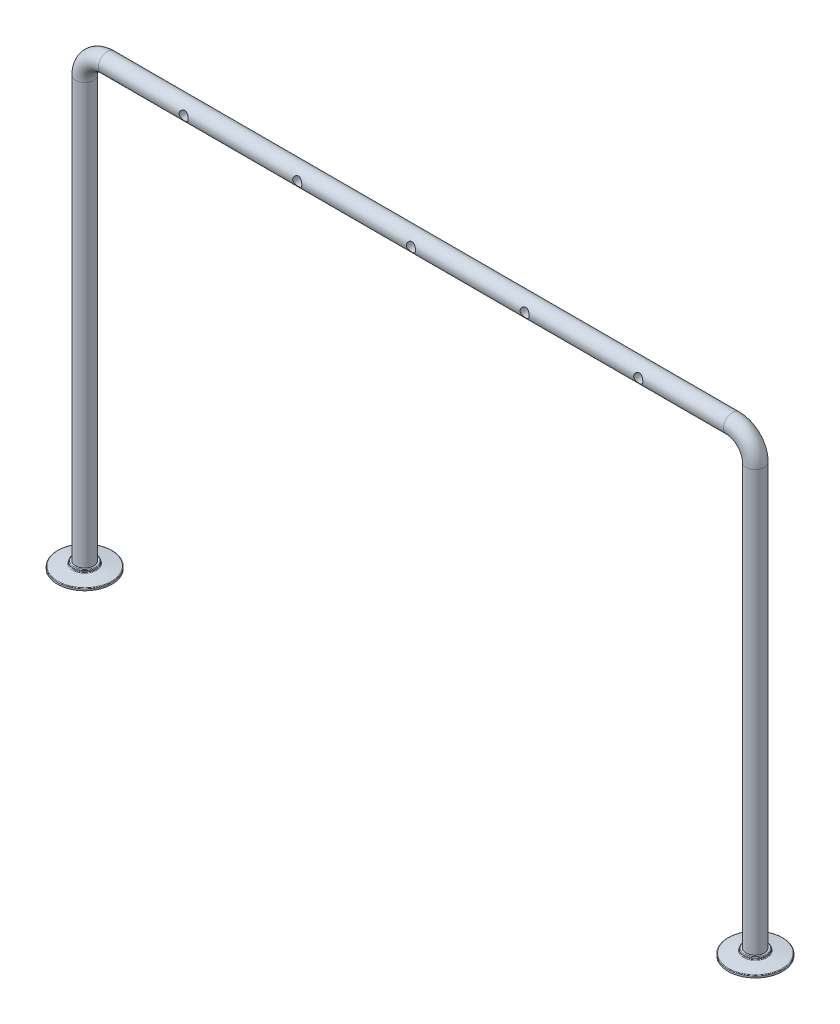
from build123d import *

# Parameters (mm, degrees)
SWEEP1_PROFILE_R   = 4
SKETCH7_R          = 2
CUT_EXTRUDE1_DEPTH = 5.0000001


with BuildPart() as part:
    # Sweep1: sweep along a path in Sketch2
    with BuildLine(Plane.XY) as sweep1_path:
        Line((-147.5, -135.613423102), (-147.5, 49.386576898))
        ThreePointArc((-147.5, 49.386576898), (-144.571067812, 56.45764471), (-137.5, 59.386576898))
        Line((-137.5, 59.386576898), (137.5, 59.386576898))
        ThreePointArc((137.5, 59.386576898), (144.571067812, 56.45764471), (147.5, 49.386576898))
        Line((147.5, 49.386576898), (147.5, -135.613423102))
    # Sweep1 profile (on start of the path) → Sweep1 (sweep)
    with BuildSketch(Plane(origin=(-147.5, -135.613423102, 0), x_dir=(1, 0, 0), z_dir=(0, 1, 0))):
        Circle(SWEEP1_PROFILE_R)
    sweep(path=sweep1_path.line)

    # Sketch7 → Cut-Extrude1 (cut, through all)
    with BuildSketch(Plane.XY):
        with Locations((-100, 59.386576898)):
            Circle(SKETCH7_R)
        with Locations((-50, 59.386576898)):
            Circle(SKETCH7_R)
        with Locations((0, 59.386576898)):
            Circle(SKETCH7_R)
        with Locations((50, 59.386576898)):
            Circle(SKETCH7_R)
        with Locations((100, 59.386576898)):
            Circle(SKETCH7_R)
    extrude(amount=CUT_EXTRUDE1_DEPTH, mode=Mode.SUBTRACT)

    # Sketch8 → Revolve1 (revolve)
    with BuildSketch(Plane.XY):
        with BuildLine():
            Line((-147.5, -135.613423102), (-152.2, -135.613423102))
            ThreePointArc((-152.2, -135.613423102), (-152.412132034, -135.701291067), (-152.5, -135.913423102))
            Line((-152.5, -135.913423102), (-152.5, -136.353234481))
            ThreePointArc((-152.5, -136.353234481), (-152.573363814, -136.549795004), (-152.757573593, -136.650219329))
            Line((-152.757573593, -136.650219329), (-159.242426407, -137.576626874))
            ThreePointArc((-159.242426407, -137.576626874), (-159.426636186, -137.6770512), (-159.5, -137.873611722))
            Line((-159.5, -137.873611722), (-159.5, -138.613423102))
            Line((-159.5, -138.613423102), (-147.5, -138.613423102))
            Line((-147.5, -138.613423102), (-147.5, -135.613423102))
        make_face()
    revolve1 = revolve(axis=Axis((-147.5, -138.613423102, 0), (0, 1, 0)))

    # Mirror1: Revolve1 across plane
    add(revolve1.mirror(Plane(origin=(0, 0, 0), x_dir=(0, 0, 1), z_dir=(1, 0, 0))))


solid = part.part
